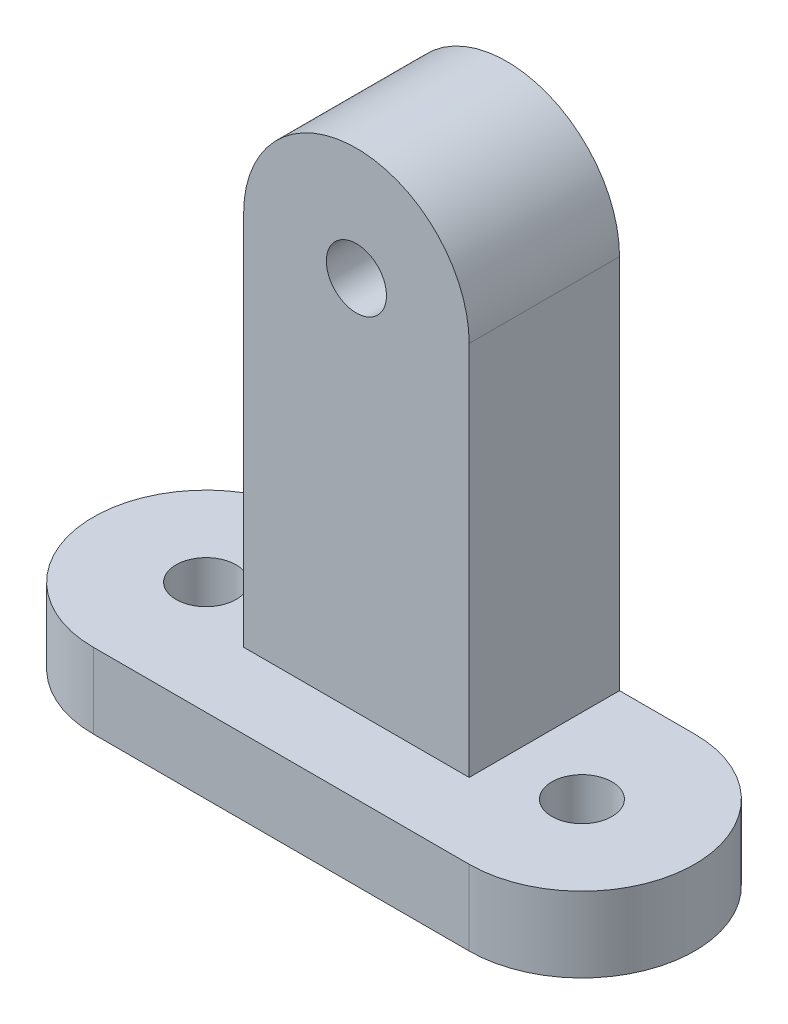
from build123d import *

# Parameters (mm, degrees)
SKETCH1_R           = 2
BOSS_EXTRUDE1_DEPTH = 5
SKETCH3_R           = 2
BOSS_EXTRUDE2_DEPTH = 10


with BuildPart() as part:
    # Sketch1 → Boss-Extrude1 (new body)
    with BuildSketch(Plane(origin=(0, 0, 0), x_dir=(1, 0, 0), z_dir=(0, 1, 0))):
        with BuildLine():
            Line((0, 0), (25, 0))
            ThreePointArc((25, 0), (32.5, 7.5), (25, 15))
            Line((25, 15), (0, 15))
            ThreePointArc((0, 15), (-7.5, 7.5), (0, 0))
        make_face()
        with Locations((0, 7.5)):
            Circle(SKETCH1_R, mode=Mode.SUBTRACT)
        with Locations((25, 7.5)):
            Circle(SKETCH1_R, mode=Mode.SUBTRACT)
    extrude(amount=BOSS_EXTRUDE1_DEPTH)

    # Sketch3 → Boss-Extrude2 (add)
    with BuildSketch(Plane(origin=(0, 0, -15), x_dir=(-1, 0, 0), z_dir=(0, 0, -1))):
        with BuildLine():
            Line((-20, 5), (-5, 5))
            Line((-5, 5), (-5, 30))
            ThreePointArc((-5, 30), (-12.5, 37.5), (-20, 30))
            Line((-20, 30), (-20, 5))
        make_face()
        with Locations((-12.5, 30)):
            Circle(SKETCH3_R, mode=Mode.SUBTRACT)
    extrude(amount=-BOSS_EXTRUDE2_DEPTH)


solid = part.part
